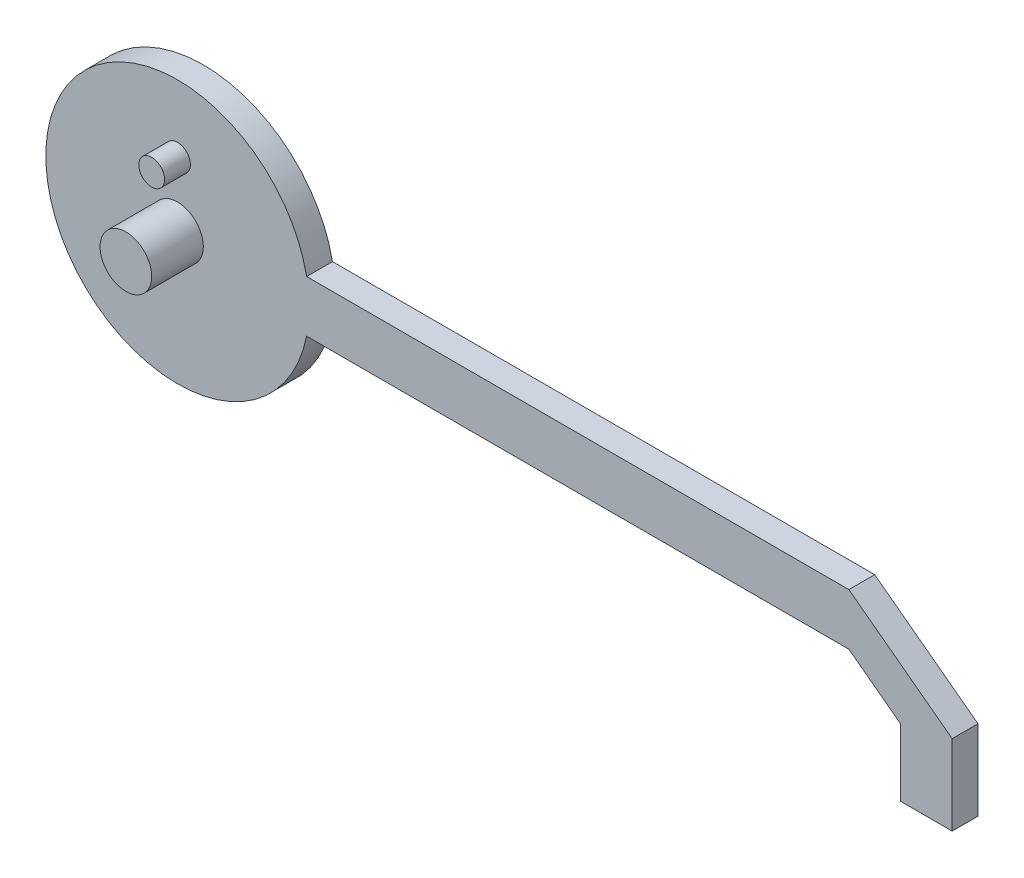
from build123d import *

# Parameters (mm, degrees)
SALIENTE_EXTRUIR1_DEPTH = 5
CROQUIS2_R              = 2.5
SALIENTE_EXTRUIR2_DEPTH = 5
CROQUIS3_R              = 5
SALIENTE_EXTRUIR3_DEPTH = 10


with BuildPart() as part:
    # Croquis1 → Saliente-Extruir1 (new body)
    with BuildSketch(Plane.XY):
        with BuildLine():
            Line((-52.49750025, 5), (52.49750025, 5))
            Line((52.49750025, 5), (72.49750025, -10))
            Line((72.49750025, -10), (72.49750025, -25.5))
            Line((72.49750025, -25.5), (62.49750025, -25.5))
            Line((62.49750025, -25.5), (62.49750025, -12.5))
            Line((62.49750025, -12.5), (52.49750025, -5))
            Line((52.49750025, -5), (-52.49750025, -5))
            ThreePointArc((-52.49750025, -5), (-103.00249975, 0), (-52.49750025, 5))
        make_face()
    extrude(amount=SALIENTE_EXTRUIR1_DEPTH)

    # Croquis2 → Saliente-Extruir2 (add)
    with BuildSketch(Plane.XY.offset(5)):
        with Locations((-77.50249975, 12.5)):
            Circle(CROQUIS2_R)
    extrude(amount=SALIENTE_EXTRUIR2_DEPTH)

    # Croquis3 → Saliente-Extruir3 (add)
    with BuildSketch(Plane.XY.offset(5)):
        with Locations((-77.50249975, 0)):
            Circle(CROQUIS3_R)
    extrude(amount=SALIENTE_EXTRUIR3_DEPTH)


solid = part.part
